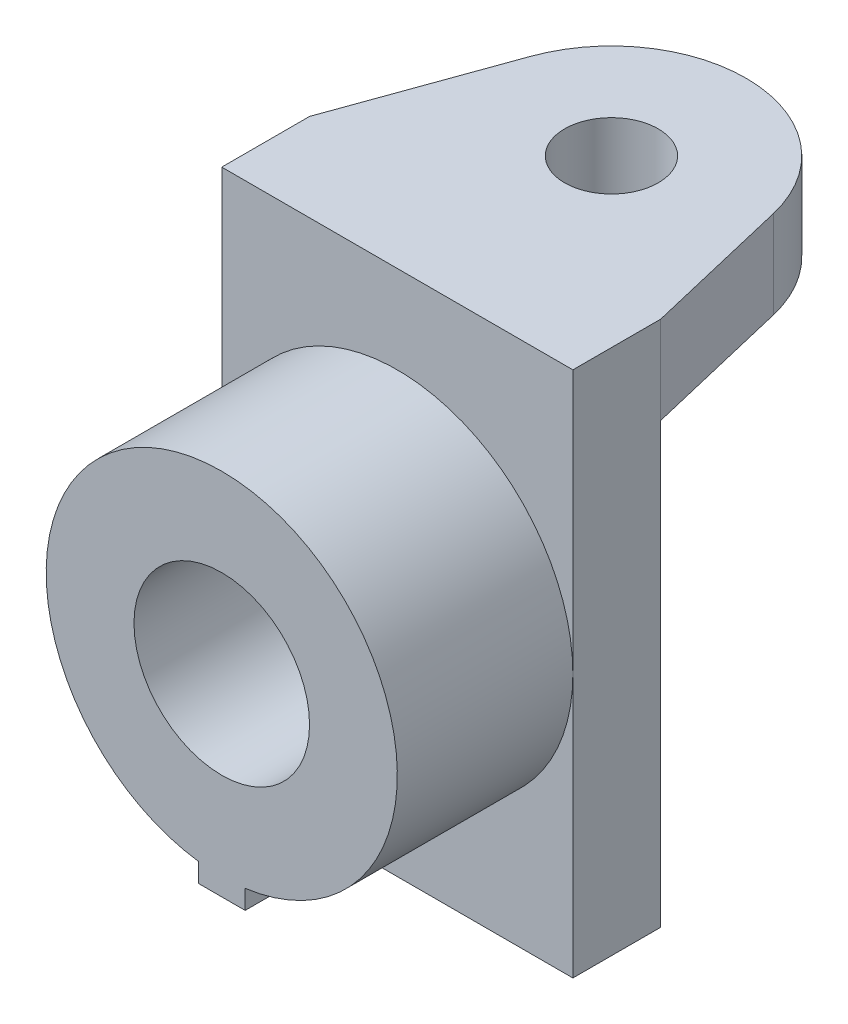
from build123d import *

# Parameters (mm, degrees)
SKETCH1_W           = 60
SKETCH1_H           = 90
BOSS_EXTRUDE1_DEPTH = 15
SKETCH2_R           = 15
BOSS_EXTRUDE2_DEPTH = 30
SKETCH3_R           = 8
BOSS_EXTRUDE5_DEPTH = 15


with BuildPart() as part:
    # Sketch1 → Boss-Extrude1 (new body)
    with BuildSketch(Plane.XY):
        with Locations((-7.135767077, -19.469160134)):
            Rectangle(SKETCH1_W, SKETCH1_H)
    extrude(amount=BOSS_EXTRUDE1_DEPTH)

    # Sketch2 → Boss-Extrude2 (add)
    with BuildSketch(Plane.XY.offset(15)):
        with BuildLine():
            Line((-11.135767077, -49.201297629), (-11.135767077, -52.469160134))
            Line((-11.135767077, -52.469160134), (-3.135767077, -52.469160134))
            Line((-3.135767077, -52.469160134), (-3.135767077, -49.201297629))
            ThreePointArc((-3.135767077, -49.201297629), (-7.135767077, 10.530839866), (-11.135767077, -49.201297629))
        make_face()
        with Locations((-7.135767077, -19.469160134)):
            Circle(SKETCH2_R, mode=Mode.SUBTRACT)
    extrude(amount=BOSS_EXTRUDE2_DEPTH)

    # Sketch3 → Boss-Extrude5 (add)
    with BuildSketch(Plane(origin=(0, 25.530839866, 0), x_dir=(1, 0, 0), z_dir=(0, 1, 0))):
        with BuildLine():
            Line((-7.135767077, 0), (-37.135767077, 0))
            Line((-37.135767077, 0), (-27.151506269, 27.74903454))
            ThreePointArc((-27.151506269, 27.74903454), (-4.217160927, 42.925858918), (16.869139504, 25.271167514))
            Line((16.869139504, 25.271167514), (22.864232923, 0))
            Line((22.864232923, 0), (-7.135767077, 0))
        make_face()
        with Locations((-5.509756001, 19.962209426)):
            Circle(SKETCH3_R, mode=Mode.SUBTRACT)
    extrude(amount=-BOSS_EXTRUDE5_DEPTH)


solid = part.part
